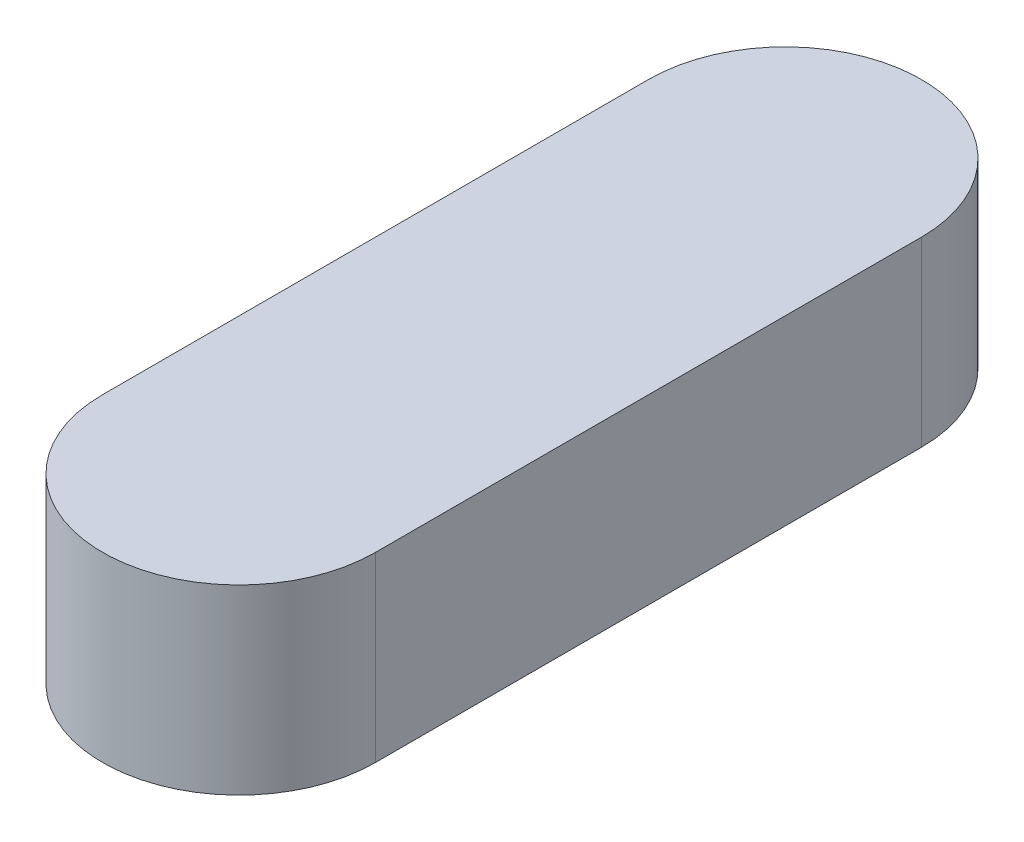
from build123d import *

# Parameters (mm, degrees)
VYSUNOUT1_DEPTH = 4


with BuildPart() as part:
    # Skica1 → Vysunout1 (new, symmetric)
    with BuildSketch(Plane(origin=(0, 0, 0), x_dir=(1, 0, 0), z_dir=(0, 1, 0))):
        with BuildLine():
            Line((-6, 12), (-6, -12))
            ThreePointArc((-6, -12), (0, -18), (6, -12))
            Line((6, -12), (6, 12))
            ThreePointArc((6, 12), (0, 18), (-6, 12))
        make_face()
    extrude(amount=VYSUNOUT1_DEPTH, both=True)


solid = part.part
